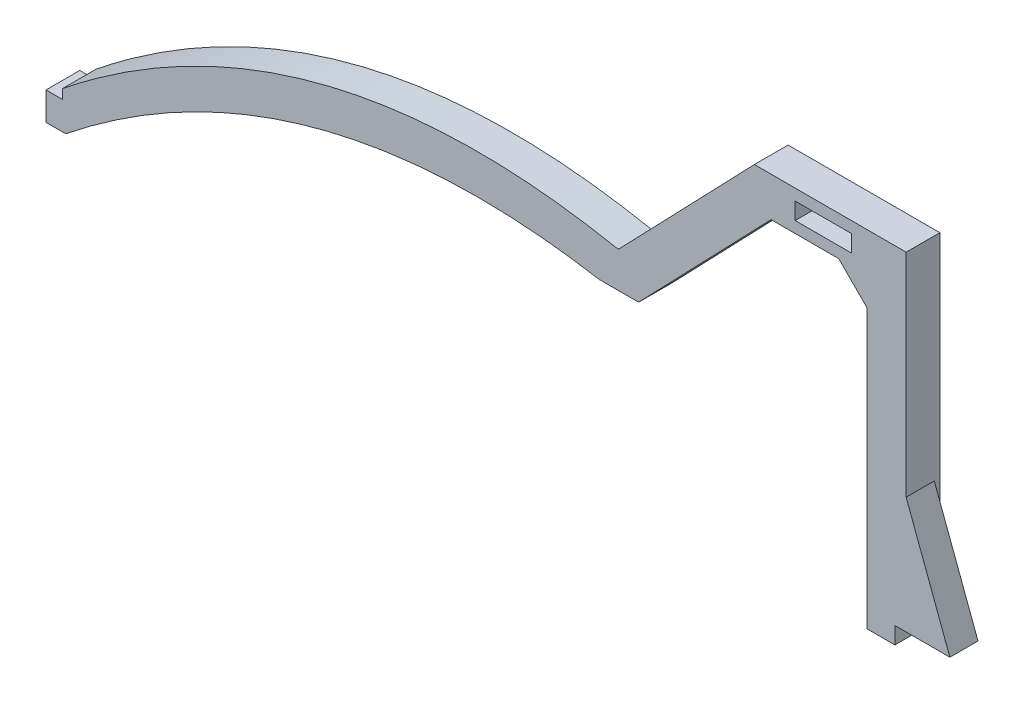
from build123d import *

# Parameters (mm, degrees)
BOSS_EXTRUDE1_DEPTH = 6
BOSS_EXTRUDE2_DEPTH = 5
CHAMFER1_SIZE       = 5
SKETCH3_W           = 10
SKETCH3_H           = 3
CUT_EXTRUDE1_DEPTH  = 6


with BuildPart() as part:
    # Sketch1 → Boss-Extrude1 (new body)
    with BuildSketch(Plane.XY):
        with BuildLine():
            Line((-0.533466094, 0), (-3.5, 0))
            Line((-3.5, 0), (-3.5, -5))
            Line((-3.5, -5), (0, -5))
            add(Edge.make_bspline(
                [(0, -5), (42.604817908, 29.035673618), (94.903787643, 20)],
                knots=[0, 0, 0, 1, 1, 1], degree=2))
            Line((94.903787643, 20), (101.903787643, 20))
            Line((101.903787643, 20), (125.469317842, 44.504980705))
            Line((125.469317842, 44.504980705), (142.489368048, 44.504980705))
            Line((142.489368048, 44.504980705), (142.489368048, -10))
            Line((142.489368048, -10), (147.489368048, -10))
            Line((147.489368048, -10), (147.489368048, -7))
            Line((147.489368048, -7), (149.489368048, -7))
            Line((149.489368048, -7), (149.489368048, 51.504980705))
            Line((149.489368048, 51.504980705), (122.489368048, 51.504980705))
            Line((122.489368048, 51.504980705), (98.295822857, 26.346948908))
            add(Edge.make_bspline(
                [(-0.533451554, 1.707670566), (28.799887609, 25.188101284), (61.717873648, 33.515524554), (98.026818716, 26.400472635), (98.295822857, 26.346948908)],
                knots=[0, 0, 0, 0, 1, 1.00745886, 1.00745886, 1.00745886, 1.00745886], degree=3))
            Line((-0.533451554, 1.707670566), (-0.533466094, 0))
        make_face()
    extrude(amount=BOSS_EXTRUDE1_DEPTH)

    # Sketch2 → Boss-Extrude2 (add)
    with BuildSketch(Plane.XY.offset(6)):
        Polygon((149.489368048, -7), (157.267488672, -7), (149.489368048, 13.763788313), align=None)
    extrude(amount=-BOSS_EXTRUDE2_DEPTH)

    # Chamfer1
    chamfer1_edges = [part.edges().sort_by_distance(p)[0] for p in [
        (142.489368048, 44.504980705, 3),
    ]]
    chamfer(chamfer1_edges, length=CHAMFER1_SIZE)

    # Sketch3 → Cut-Extrude1 (cut)
    with BuildSketch(Plane.XY.offset(6)):
        with Locations((134.74873736, 48.004980705)):
            Rectangle(SKETCH3_W, SKETCH3_H)
    extrude(amount=-CUT_EXTRUDE1_DEPTH, mode=Mode.SUBTRACT)


solid = part.part
